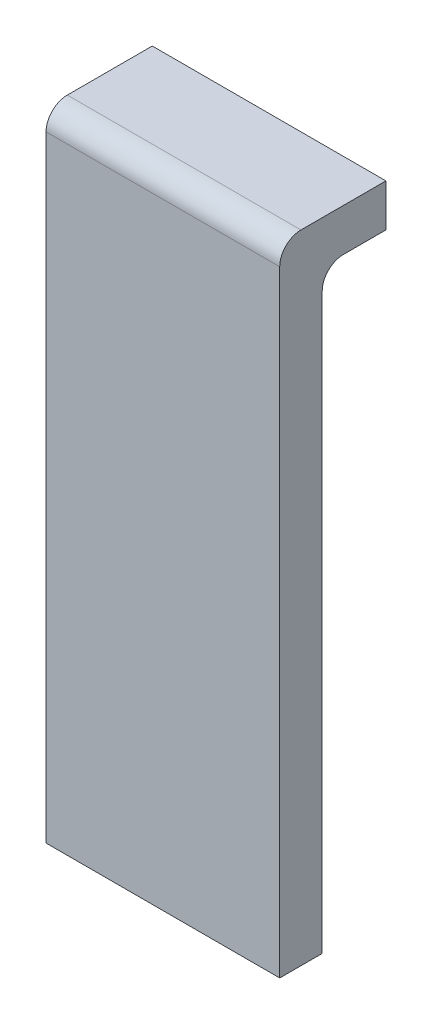
from build123d import *

# Parameters (mm, degrees)
ESQUISSE1_W        = 1.1
ESQUISSE1_H        = 3
BOSS_EXTRU_1_DEPTH = 0.2
ESQUISSE2_W        = 1.1
ESQUISSE2_H        = 0.2
BOSS_EXTRU_2_DEPTH = 0.3
CONG_1_R           = 0.1


with BuildPart() as part:
    # Esquisse1 → Boss.-Extru.1 (new body)
    with BuildSketch(Plane.XY):
        with Locations((0.55, 1.5)):
            Rectangle(ESQUISSE1_W, ESQUISSE1_H)
    extrude(amount=-BOSS_EXTRU_1_DEPTH)

    # Esquisse2 → Boss.-Extru.2 (add)
    with BuildSketch(Plane(origin=(0, 0, -0.2), x_dir=(-1, 0, 0), z_dir=(0, 0, -1))):
        with Locations((-0.55, 2.9)):
            Rectangle(ESQUISSE2_W, ESQUISSE2_H)
    extrude(amount=BOSS_EXTRU_2_DEPTH)

    # Congé1
    cong_1_edges = [part.edges().sort_by_distance(p)[0] for p in [
        (0.55, 3, 0),
        (0.55, 2.8, -0.2),
    ]]
    fillet(cong_1_edges, radius=CONG_1_R)


solid = part.part
